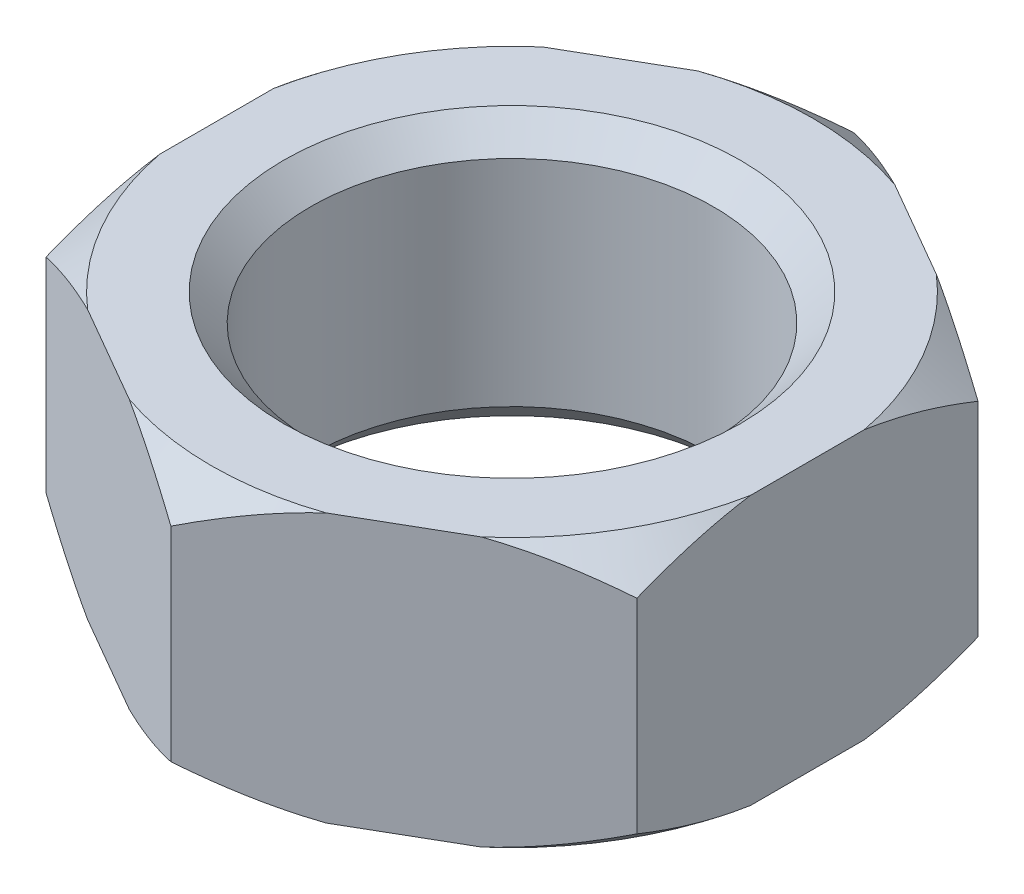
from build123d import *

# Parameters (mm, degrees)
BOSS_EXTRUDE1_DEPTH = 10
SKETCH4_R           = 7.5
CUT_EXTRUDE1_DEPTH  = 11
CHAMFER1_SIZE       = 1


with BuildPart() as part:
    # Sketch3 → Boss-Extrude1 (new body)
    with BuildSketch(Plane(origin=(0, 0, 0), x_dir=(1, 0, 0), z_dir=(0, 1, 0))):
        Polygon((-11, 6.350852961), (-11, -6.350852961), (0, -12.701705922), (11, -6.350852961), (11, 6.350852961), (0, 12.701705922), align=None)
    extrude(amount=BOSS_EXTRUDE1_DEPTH)

    # Sketch4 → Cut-Extrude1 (cut, through all)
    with BuildSketch(Plane(origin=(0, 10, 0), x_dir=(1, 0, 0), z_dir=(0, 1, 0))):
        Circle(SKETCH4_R)
    extrude(amount=-CUT_EXTRUDE1_DEPTH, mode=Mode.SUBTRACT)

    # Chamfer1
    chamfer1_edges = [part.edges().sort_by_distance(p)[0] for p in [
        (-7.5, 0, 0),
        (-7.5, 10, 0),
    ]]
    chamfer(chamfer1_edges, length=CHAMFER1_SIZE)

    # Sketch5 → Cut-Revolve1 (revolve, cut)
    with BuildSketch(Plane(origin=(0, 0, 0), x_dir=(0, 0, -1), z_dir=(1, 0, 0))):
        Polygon((-12.701705922, 10), (-12.701705922, 8.8), (-11.201705922, 10), align=None)
        Polygon((-12.701705922, 0), (-12.701705922, 1.2), (-11.201705922, 0), align=None)
    revolve(axis=Axis((0, 13.174691504, 0), (0, -1, 0)), mode=Mode.SUBTRACT)


solid = part.part
